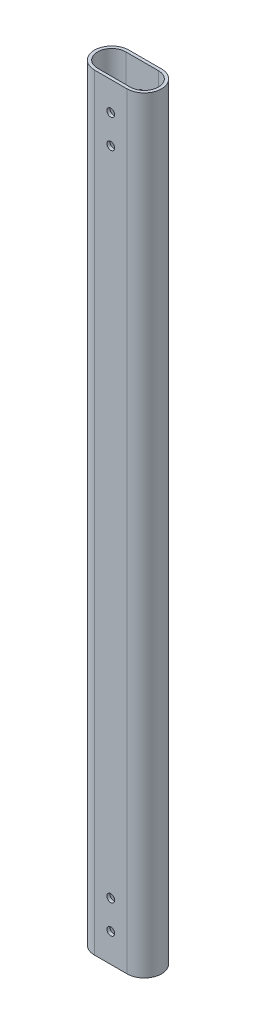
from build123d import *

# Parameters (mm, degrees)
EXTRUDE_1_DEPTH       = 400
HOLE_WIZARD_10_32_1_D = 4.0386


with BuildPart() as part:
    # 草圖1 → 填料-伸長1 (new body)
    with BuildSketch(Plane(origin=(0, 0, 0), x_dir=(1, 0, 0), z_dir=(0, 1, 0))):
        with BuildLine():
            Line((8.5, 9), (-8.5, 9))
            ThreePointArc((-8.5, 9), (-17.5, 0), (-8.5, -9))
            Line((-8.5, -9), (8.5, -9))
            ThreePointArc((8.5, -9), (17.5, 0), (8.5, 9))
        make_face()
        with BuildLine():
            Line((8.5, -7.4), (-8.5, -7.4))
            ThreePointArc((-8.5, -7.4), (-15.9, 0), (-8.5, 7.4))
            Line((-8.5, 7.4), (8.5, 7.4))
            ThreePointArc((8.5, 7.4), (15.9, 0), (8.5, -7.4))
        make_face(mode=Mode.SUBTRACT)
    extrude(amount=EXTRUDE_1_DEPTH)

    # #10-32 螺紋孔1 (through all)
    with Locations(Plane.XY.offset(9)):
        with Locations((0, 30), (0, 15), (0, 385), (0, 370)):
            Hole(HOLE_WIZARD_10_32_1_D / 2)


solid = part.part
